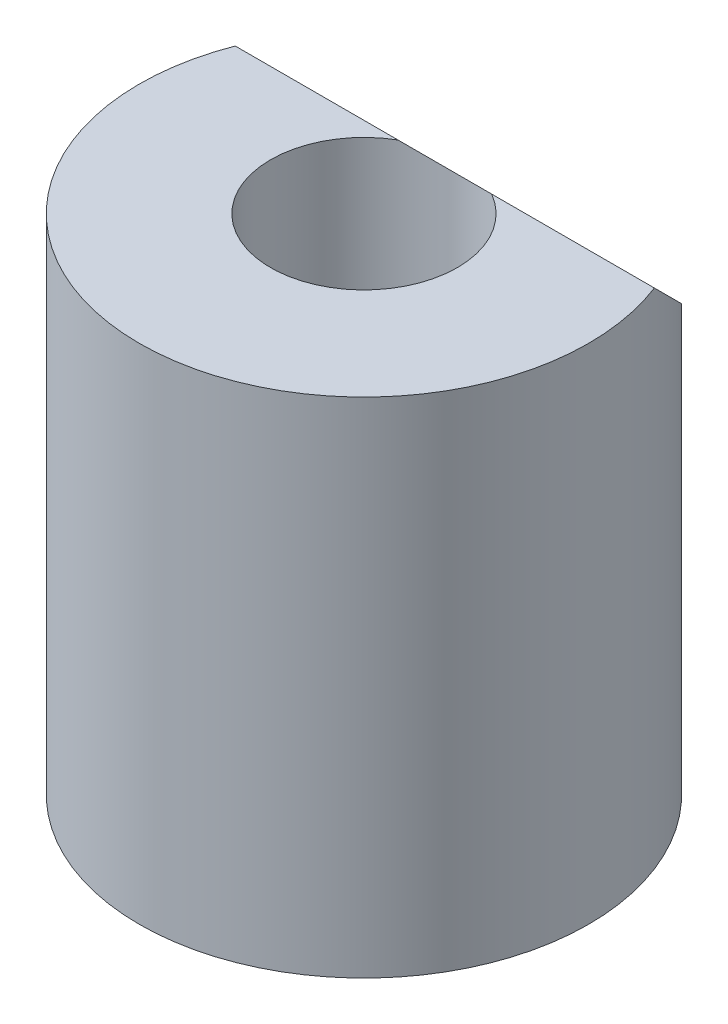
from build123d import *

# Parameters (mm, degrees)
SKETCH1_R           = 6.25
BOSS_EXTRUDE1_DEPTH = 14
SKETCH2_R           = 2.6
CUT_EXTRUDE1_DEPTH  = 14
CUT_EXTRUDE2_DEPTH  = 7
SKETCH4_R           = 4.5
CUT_EXTRUDE3_DEPTH  = 4


with BuildPart() as part:
    # Sketch1 → Boss-Extrude1 (new body)
    with BuildSketch(Plane(origin=(0, 0, 0), x_dir=(1, 0, 0), z_dir=(0, 1, 0))):
        Circle(SKETCH1_R)
    extrude(amount=BOSS_EXTRUDE1_DEPTH)

    # Sketch2 → Cut-Extrude1 (cut)
    with BuildSketch(Plane(origin=(0, 14, 0), x_dir=(1, 0, 0), z_dir=(0, 1, 0))):
        Circle(SKETCH2_R)
    extrude(amount=-CUT_EXTRUDE1_DEPTH, mode=Mode.SUBTRACT)

    # Sketch3 → Cut-Extrude2 (cut, symmetric)
    with BuildSketch(Plane(origin=(0, 0, 0), x_dir=(0, 0, -1), z_dir=(1, 0, 0))):
        Polygon((2.25, 14), (6.25, 10), (6.25, 14), align=None)
    extrude(amount=CUT_EXTRUDE2_DEPTH, both=True, mode=Mode.SUBTRACT)

    # Sketch4 → Cut-Extrude3 (cut)
    with BuildSketch(Plane.XZ):
        Circle(SKETCH4_R)
    extrude(amount=-CUT_EXTRUDE3_DEPTH, mode=Mode.SUBTRACT)


solid = part.part
